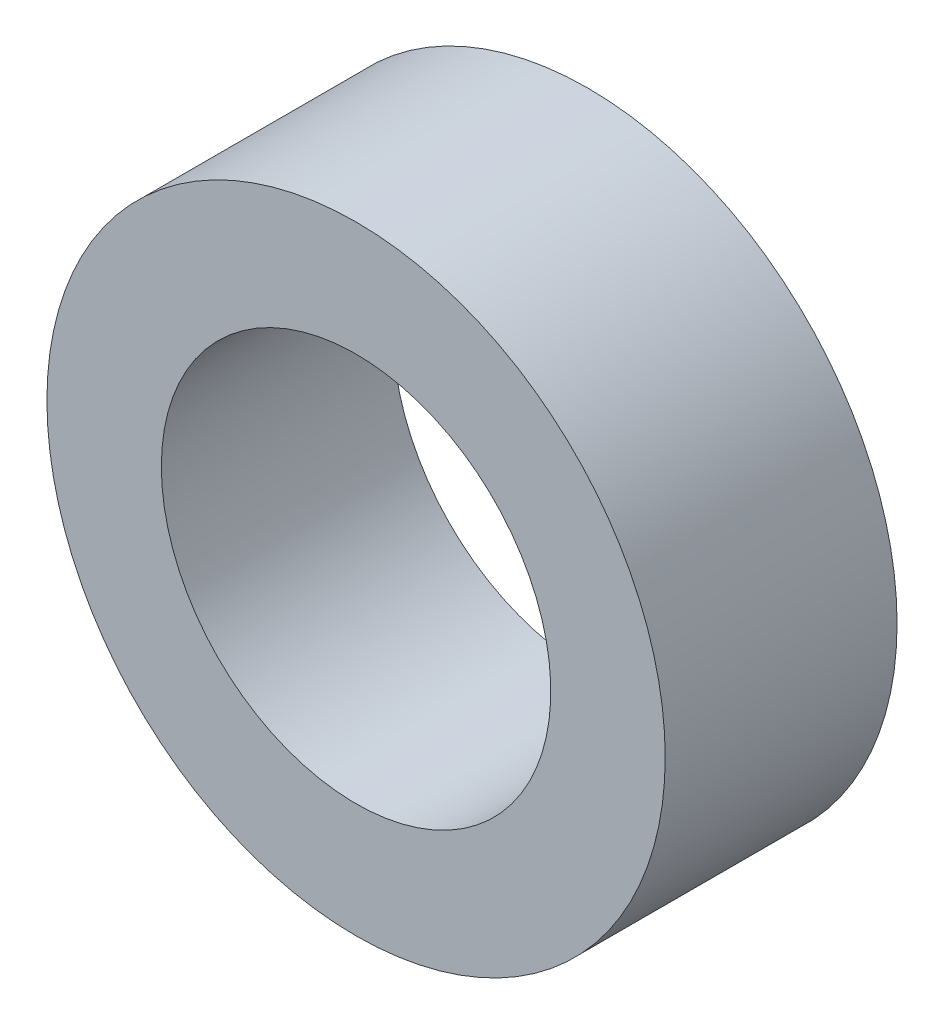
from build123d import *

# Parameters (mm, degrees)
SKETCH1_R           = 6.35
BOSS_EXTRUDE1_DEPTH = 4.7625
SKETCH1_3_R         = 4
CUT_EXTRUDE1_DEPTH  = 4.7625


with BuildPart() as part:
    # Sketch1 → Boss-Extrude1 (new body)
    with BuildSketch(Plane(origin=(0, 0, 1577.629912845), x_dir=(-1, 0, 0), z_dir=(0, 0, -1))):
        with Locations((-226.780244033, 617.20159627)):
            Circle(SKETCH1_R)
    extrude(amount=BOSS_EXTRUDE1_DEPTH)

    # Sketch1_3 → Cut-Extrude1 (cut)
    with BuildSketch(Plane(origin=(0, 0, 1577.629912845), x_dir=(-1, 0, 0), z_dir=(0, 0, -1))):
        with Locations((-226.780244033, 617.20159627)):
            Circle(SKETCH1_3_R)
    extrude(amount=CUT_EXTRUDE1_DEPTH, mode=Mode.SUBTRACT)


solid = part.part
